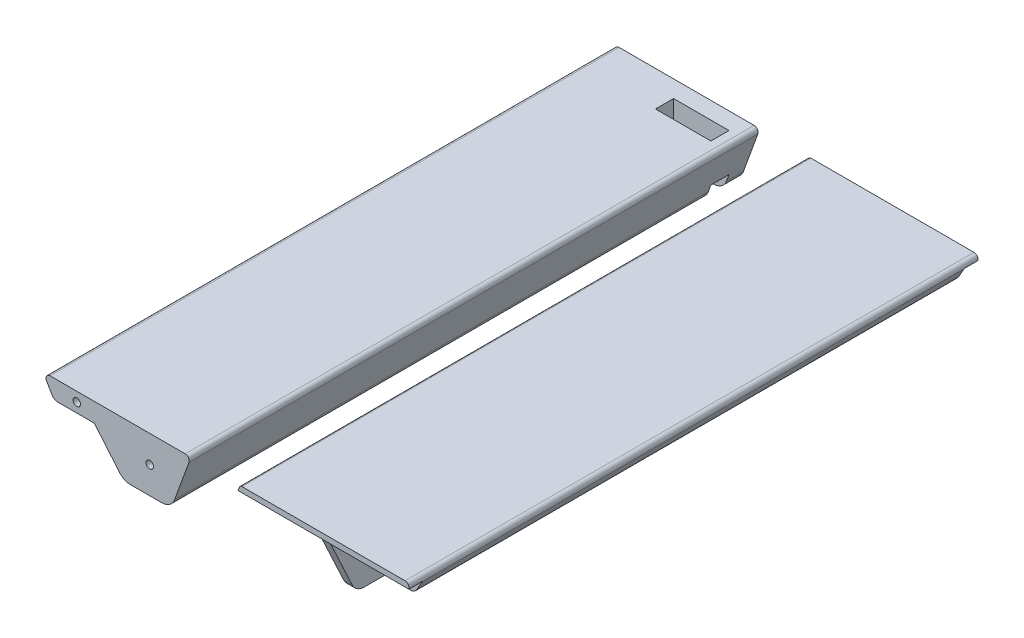
from build123d import *

# Parameters (mm, degrees)
BOSS_EXTRUDE1_DEPTH   = 105.25
SKETCH1_W             = 6
SKETCH1_H             = 2.5
BOSS_EXTRUDE1_2_DEPTH = 105.25
SKETCH2_R             = 1.375
CUT_EXTRUDE1_DEPTH    = 15
CUT_EXTRUDE2_DEPTH    = 5
FILLET1_R             = 5
SKETCH4_R             = 1.375
CUT_EXTRUDE3_DEPTH    = 3.15
FILLET2_R             = 5
SKETCH5_W             = 20.5
SKETCH5_H             = 6.7
CUT_EXTRUDE4_DEPTH    = 23
SKETCH6_R             = 1.125
CUT_EXTRUDE5_DEPTH    = 20
CUT_EXTRUDE6_START    = -6.3
SKETCH7_R             = 2.5
CUT_EXTRUDE6_DEPTH    = 6.3


with BuildPart() as part:
    # Sketch1 → Boss-Extrude1 (new body)
    with BuildSketch(Plane.XY):
        with BuildLine():
            Line((0, 0), (50, 0))
            ThreePointArc((50, 0), (51.228728066, -0.639635345), (51.409538931, -2.013030215))
            Line((51.409538931, -2.013030215), (44.862817325, -20))
            Line((44.862817325, -20), (27.295046551, -20))
            Line((27.295046551, -20), (16.386751346, -7))
            Line((16.386751346, -7), (2.886751346, -7))
            ThreePointArc((2.886751346, -7), (1.636751346, -6.665063509), (0.721687836, -5.75))
            Line((0.721687836, -5.75), (-1.299038106, -2.25))
            ThreePointArc((-1.299038106, -2.25), (-1.299038106, -0.75), (0, 0))
        make_face()
    extrude(amount=BOSS_EXTRUDE1_DEPTH)

    # Sketch2 → Cut-Extrude1 (cut)
    with BuildSketch(Plane.XY.offset(105.25)):
        with Locations((9.886751346, -3.5)):
            Circle(SKETCH2_R)
        with Locations((36.886751346, -10)):
            Circle(SKETCH2_R)
    extrude(amount=-CUT_EXTRUDE1_DEPTH, mode=Mode.SUBTRACT)

    # Mirror1: part across plane


with BuildPart() as body_2:
    # Sketch1 → Boss-Extrude1 2 (new body)
    with BuildSketch(Plane.XY):
        with BuildLine():
            Line((71, 0), (131.333502692, 0))
            ThreePointArc((131.333502692, 0), (132.632540798, -0.75), (132.632540798, -2.25))
            Line((132.632540798, -2.25), (130.611814855, -5.75))
            ThreePointArc((130.611814855, -5.75), (129.696751346, -6.665063509), (128.446751346, -7))
            Line((128.446751346, -7), (122.816751346, -7))
            Line((122.816751346, -7), (122.816751346, -2))
            Line((122.816751346, -2), (103.816751346, -2))
            Line((103.816751346, -2), (103.816751346, -22))
            Line((103.816751346, -22), (100.666751346, -22))
            Line((100.666751346, -22), (100.666751346, -2))
            Line((100.666751346, -2), (69.571851993, -2))
            Line((69.571851993, -2), (70.060307379, -0.657979857))
            ThreePointArc((70.060307379, -0.657979857), (70.426423564, -0.180847956), (71, 0))
        make_face()
        with Locations((126.816751346, -3.25)):
            Rectangle(SKETCH1_W, SKETCH1_H, mode=Mode.SUBTRACT)
    extrude(amount=BOSS_EXTRUDE1_2_DEPTH)

    # Sketch3 → Cut-Extrude2 (cut)
    with BuildSketch(Plane.XY.offset(105.25)):
        with BuildLine():
            Line((122.816751346, -2), (132.747716254, -2))
            ThreePointArc((132.747716254, -2), (132.695875128, -2.12764747), (132.632540798, -2.25))
            Line((132.632540798, -2.25), (130.611814855, -5.75))
            ThreePointArc((130.611814855, -5.75), (129.696751346, -6.665063509), (128.446751346, -7))
            Line((128.446751346, -7), (122.816751346, -7))
            Line((122.816751346, -7), (122.816751346, -2))
        make_face()
    extrude(amount=-CUT_EXTRUDE2_DEPTH, mode=Mode.SUBTRACT)

    # Mirror1 2: body 2 across plane


with BuildPart() as part_1:
    add(part.part)
    add(part.part.mirror(Plane(origin=(0, -1.5, 0), x_dir=(1, 0, 0), z_dir=(0, 0, -1))))

    # Fillet1
    fillet1_edges = [part_1.edges().sort_by_distance(p)[0] for p in [
        (44.862817325, -20, 0),
        (27.295046551, -20, 0),
    ]]
    fillet(fillet1_edges, radius=FILLET1_R)

    # Sketch5 → Cut-Extrude4 (cut, through all)
    with BuildSketch(Plane(origin=(0, 0, 0), x_dir=(1, 0, 0), z_dir=(0, 1, 0))):
        with Locations((36.75, 95.6)):
            Rectangle(SKETCH5_W, SKETCH5_H)
    extrude(amount=-CUT_EXTRUDE4_DEPTH, mode=Mode.SUBTRACT)

    # Sketch6 → Cut-Extrude5 (cut)
    with BuildSketch(Plane(origin=(0, 0, -105.25), x_dir=(-1, 0, 0), z_dir=(0, 0, -1))):
        with Locations((-41.5, -11.2)):
            Circle(SKETCH6_R)
        with Locations((-32, -11.2)):
            Circle(SKETCH6_R)
    extrude(amount=-CUT_EXTRUDE5_DEPTH, mode=Mode.SUBTRACT)

    # Sketch7 → Cut-Extrude6 (cut)
    with BuildSketch(Plane(origin=(0, 0, -105.25), x_dir=(-1, 0, 0), z_dir=(0, 0, -1)).offset(CUT_EXTRUDE6_START)):
        with Locations((-41.5, -11.2)):
            Circle(SKETCH7_R)
        with Locations((-32, -11.2)):
            Circle(SKETCH7_R)
    extrude(amount=CUT_EXTRUDE6_DEPTH, mode=Mode.SUBTRACT)


with BuildPart() as body_2_1:
    add(body_2.part)
    add(body_2.part.mirror(Plane(origin=(0, -1.5, 0), x_dir=(1, 0, 0), z_dir=(0, 0, -1))))

    # Sketch4 → Cut-Extrude3 (cut)
    with BuildSketch(Plane(origin=(103.816751346, 0, 0), x_dir=(0, 0, -1), z_dir=(1, 0, 0))):
        with Locations((-81.25, -17)):
            Circle(SKETCH4_R)
        with Locations((-61.25, -17)):
            Circle(SKETCH4_R)
        with Locations((-41.25, -17)):
            Circle(SKETCH4_R)
        with Locations((-21.25, -17)):
            Circle(SKETCH4_R)
        with Locations((-1.25, -17)):
            Circle(SKETCH4_R)
        with Locations((18.75, -17)):
            Circle(SKETCH4_R)
        with Locations((38.75, -17)):
            Circle(SKETCH4_R)
        with Locations((58.75, -17)):
            Circle(SKETCH4_R)
        with Locations((78.75, -17)):
            Circle(SKETCH4_R)
        Polygon((-105.25, -22), (-105.25, -2), (-95.923846837, -22), align=None)
        Polygon((105.25, -2), (90.25, -2), (80.923846837, -22), (105.25, -22), align=None)
    extrude(amount=-CUT_EXTRUDE3_DEPTH, mode=Mode.SUBTRACT)

    # Fillet2
    fillet2_edges = [body_2_1.edges().sort_by_distance(p)[0] for p in [
        (102.241751346, -22, 95.923846837),
        (102.241751346, -22, -80.923846837),
    ]]
    fillet(fillet2_edges, radius=FILLET2_R)


solid = Compound([part_1.part, body_2_1.part])
